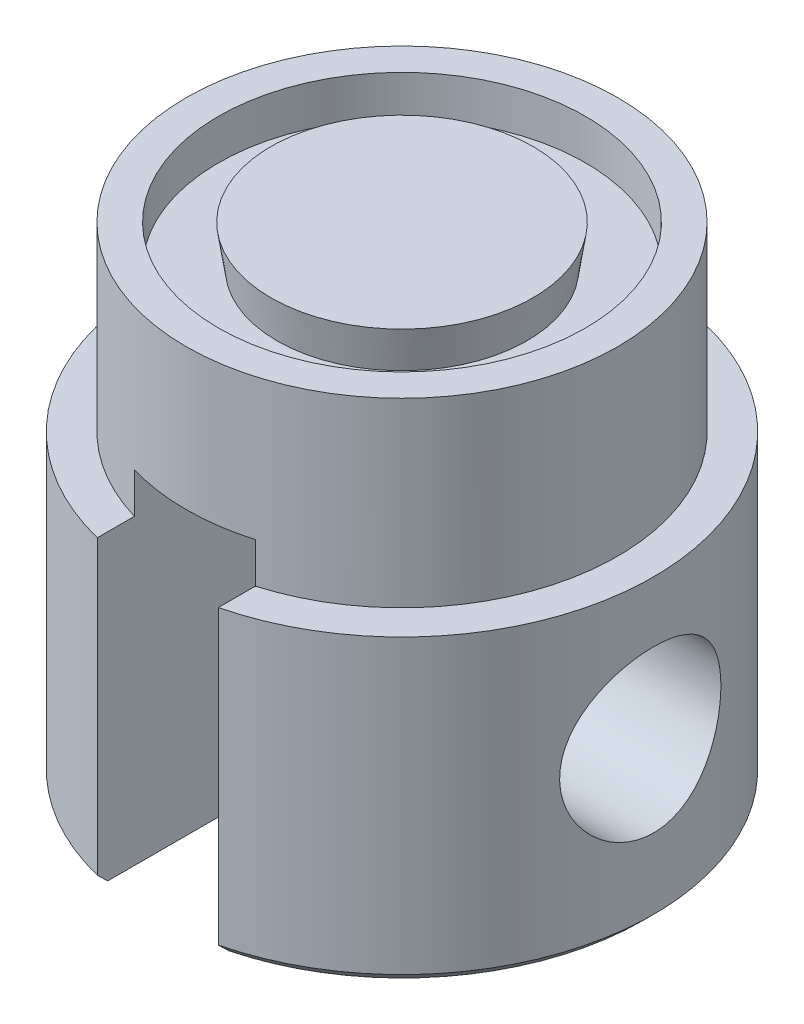
from build123d import *

# Parameters (mm, degrees)
SKETCH2_W               = 6
SKETCH2_H               = 17
CUT_EXTRUDE1_DEPTH      = 13.475
CUT_EXTRUDE1_DEPTH_BACK = 13.475
SKETCH3_R               = 4
CUT_EXTRUDE2_DEPTH      = 13.475
CUT_EXTRUDE2_DEPTH_BACK = 13.475
CHAMFER1_SIZE           = 0.5


with BuildPart() as part:
    # Sketch1 → Revolve1 (revolve)
    with BuildSketch(Plane.XY, mode=Mode.PRIVATE) as revolve1_sk:
        Polygon((-9.1, 0), (-9.1, -2), (-6.2, -2), (-6.5, 0), (0, 0), (0, -24), (-12.475, -24), (-12.475, -9), (-10.7, -9), (-10.7, 0), align=None)
    revolve(revolve1_sk.sketch.rotate(Axis((0, 0, 0), (0, -1, 0)), 270), axis=Axis((0, 0, 0), (0, -1, 0)))  # turned: the seam where the file's is

    # Sketch2 → Cut-Extrude1 (cut, two sides)
    with BuildSketch(Plane.XY) as cut_extrude1_sk:
        with Locations((0, -15.5)):
            Rectangle(SKETCH2_W, SKETCH2_H)
    extrude(amount=CUT_EXTRUDE1_DEPTH, mode=Mode.SUBTRACT)
    extrude(cut_extrude1_sk.sketch, amount=-CUT_EXTRUDE1_DEPTH_BACK, mode=Mode.SUBTRACT)

    # Sketch3 → Cut-Extrude2 (cut, two sides)
    with BuildSketch(Plane(origin=(0, 0, 0), x_dir=(0, 0, -1), z_dir=(1, 0, 0))) as cut_extrude2_sk:
        with Locations((0, -16)):
            Circle(SKETCH3_R)
    extrude(amount=CUT_EXTRUDE2_DEPTH, mode=Mode.SUBTRACT)
    extrude(cut_extrude2_sk.sketch, amount=-CUT_EXTRUDE2_DEPTH_BACK, mode=Mode.SUBTRACT)

    # Chamfer1
    chamfer1_edges = [part.edges().sort_by_distance(p)[0] for p in [
        (12.475, -24, 0),
        (-12.475, -24, 0),
    ]]
    chamfer(chamfer1_edges, length=CHAMFER1_SIZE)


solid = part.part
